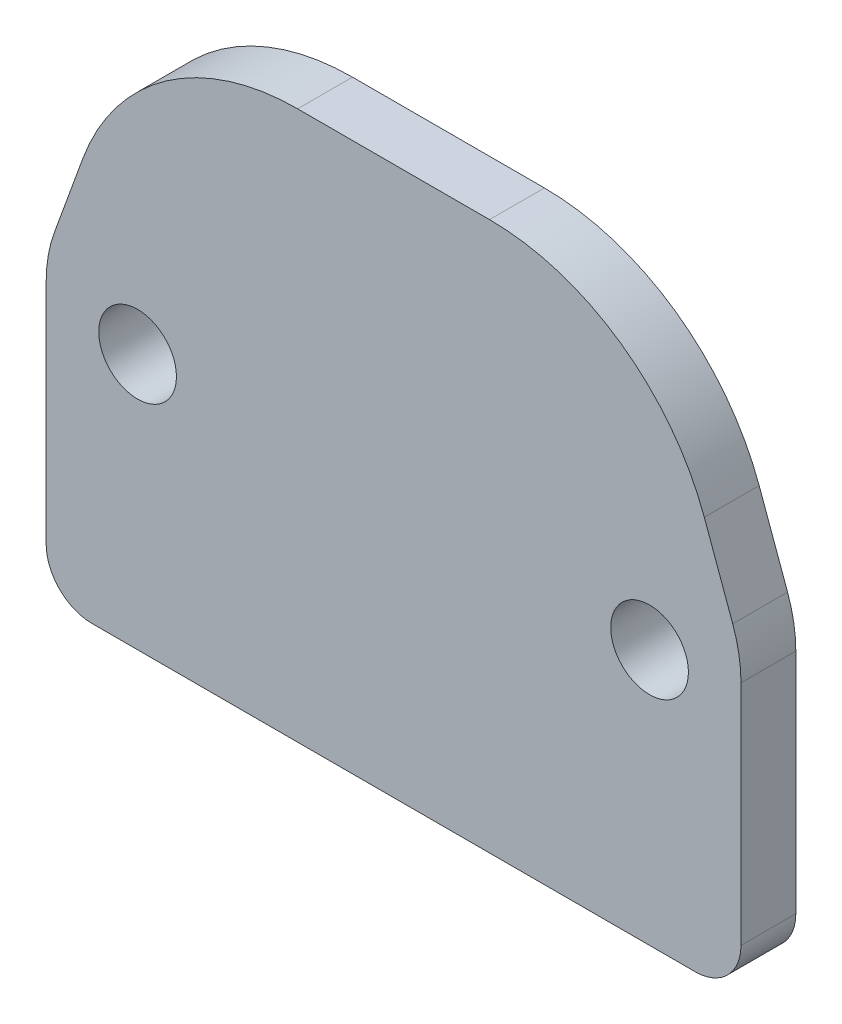
from build123d import *

# Parameters (mm, degrees)
SKETCH1_R      = 4.25
EXTRUDE1_DEPTH = 6


with BuildPart() as part:
    # Sketch1 → Extrude1 (new body)
    with BuildSketch(Plane.XY):
        with BuildLine():
            Line((38, -55), (38, -30.119678905))
            ThreePointArc((38, -30.119678905), (37.772116295, -27.51495624), (37.095389312, -24.989376755))
            Line((37.095389312, -24.989376755), (33.987127064, -16.449496417))
            ThreePointArc((33.987127064, -16.449496417), (24.834222454, -4.521198893), (10.494811545, 0))
            Line((10.494811545, 0), (-10.494811545, 0))
            ThreePointArc((-10.494811545, 0), (-24.834222454, -4.521198893), (-33.987127064, -16.449496417))
            Line((-33.987127064, -16.449496417), (-37.095389312, -24.989376755))
            ThreePointArc((-37.095389312, -24.989376755), (-37.772116295, -27.51495624), (-38, -30.119678905))
            Line((-38, -30.119678905), (-38, -55))
            ThreePointArc((-38, -55), (-36.535533906, -58.535533906), (-33, -60))
            Line((-33, -60), (33, -60))
            ThreePointArc((33, -60), (36.535533906, -58.535533906), (38, -55))
        make_face()
        with Locations((-28, -32)):
            Circle(SKETCH1_R, mode=Mode.SUBTRACT)
        with Locations((28, -32)):
            Circle(SKETCH1_R, mode=Mode.SUBTRACT)
    extrude(amount=EXTRUDE1_DEPTH)


solid = part.part
